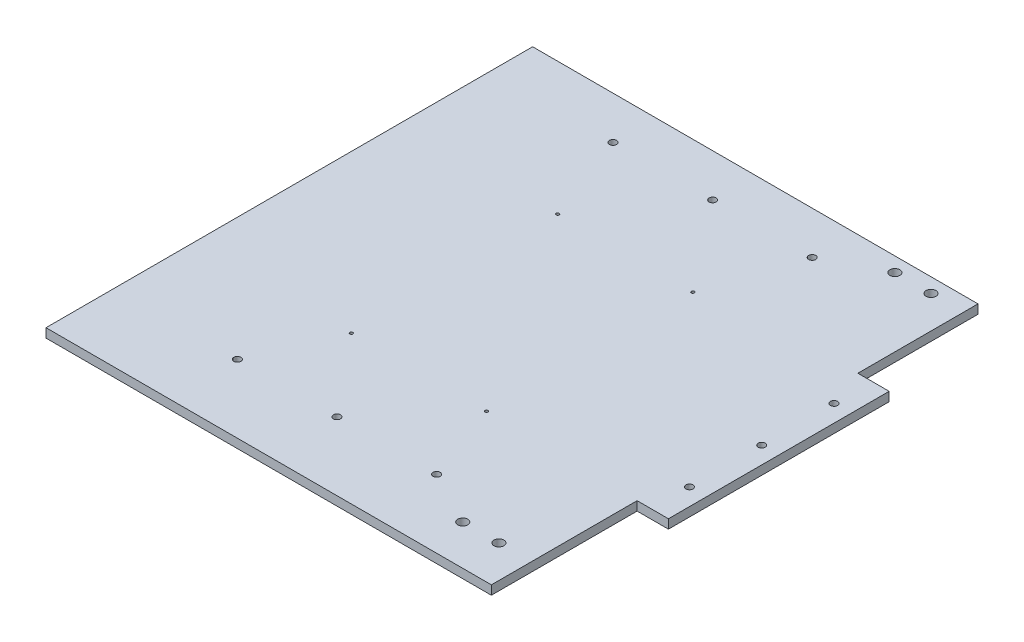
from build123d import *

# Parameters (mm, degrees)
SKETCH1_W           = 313
SKETCH1_H           = 342
BOSS_EXTRUDE1_DEPTH = 6.35
SKETCH3_W           = 22
SKETCH3_H           = 155.14040353
SKETCH3_R           = 2.5
BOSS_EXTRUDE2_DEPTH = 6.35
SKETCH2_R           = 2.5
CUT_EXTRUDE1_DEPTH  = 7.35
SKETCH4_R           = 3.5
CUT_EXTRUDE2_DEPTH  = 7.35
SKETCH5_R           = 1.05
CUT_EXTRUDE3_DEPTH  = 7.35


with BuildPart() as part:
    # Sketch1 → Boss-Extrude1 (new body)
    with BuildSketch(Plane(origin=(0, 0, 0), x_dir=(1, 0, 0), z_dir=(0, 1, 0))):
        Rectangle(SKETCH1_W, SKETCH1_H)
    extrude(amount=-BOSS_EXTRUDE1_DEPTH)

    # Sketch3 → Boss-Extrude2 (add)
    with BuildSketch(Plane(origin=(0, 0, 0), x_dir=(1, 0, 0), z_dir=(0, 1, 0))):
        with Locations((167.5, 9)):
            Rectangle(SKETCH3_W, SKETCH3_H)
        with Locations((166.5, 9)):
            Circle(SKETCH3_R, mode=Mode.SUBTRACT)
        with Locations((166.5, -41.8)):
            Circle(SKETCH3_R, mode=Mode.SUBTRACT)
        with Locations((166.5, 59.8)):
            Circle(SKETCH3_R, mode=Mode.SUBTRACT)
    extrude(amount=-BOSS_EXTRUDE2_DEPTH)

    # Sketch2 → Cut-Extrude1 (cut, through all)
    with BuildSketch(Plane(origin=(0, 0, 0), x_dir=(1, 0, 0), z_dir=(0, 1, 0))):
        with Locations((0, -123)):
            Circle(SKETCH2_R)
        with Locations((-70, -123)):
            Circle(SKETCH2_R)
        with Locations((70, -123)):
            Circle(SKETCH2_R)
        with Locations((-70, 141)):
            Circle(SKETCH2_R)
        with Locations((0, 141)):
            Circle(SKETCH2_R)
        with Locations((70, 141)):
            Circle(SKETCH2_R)
    extrude(amount=-CUT_EXTRUDE1_DEPTH, mode=Mode.SUBTRACT)

    # Sketch4 → Cut-Extrude2 (cut, through all)
    with BuildSketch(Plane(origin=(0, 0, 0), x_dir=(1, 0, 0), z_dir=(0, 1, 0))):
        with Locations((133.64, -142.84)):
            Circle(SKETCH4_R)
        with Locations((108.24, -142.84)):
            Circle(SKETCH4_R)
    cut_extrude2 = extrude(amount=-CUT_EXTRUDE2_DEPTH, mode=Mode.SUBTRACT)

    # Mirror1: Cut-Extrude2 across plane
    add(cut_extrude2.mirror(Plane(origin=(0, 0, -9), x_dir=(1, 0, 0), z_dir=(0, 0, -1))), mode=Mode.SUBTRACT)

    # Sketch5 → Cut-Extrude3 (cut, through all)
    with BuildSketch(Plane(origin=(0, 0, 0), x_dir=(1, 0, 0), z_dir=(0, 1, 0))):
        with Locations((49.149172759, 77.943976756)):
            Circle(SKETCH5_R)
        with Locations((49.149172759, -67.056023244)):
            Circle(SKETCH5_R)
        with Locations((-45.850827241, 77.943976756)):
            Circle(SKETCH5_R)
        with Locations((-45.850827241, -67.056023244)):
            Circle(SKETCH5_R)
    extrude(amount=-CUT_EXTRUDE3_DEPTH, mode=Mode.SUBTRACT)


solid = part.part
